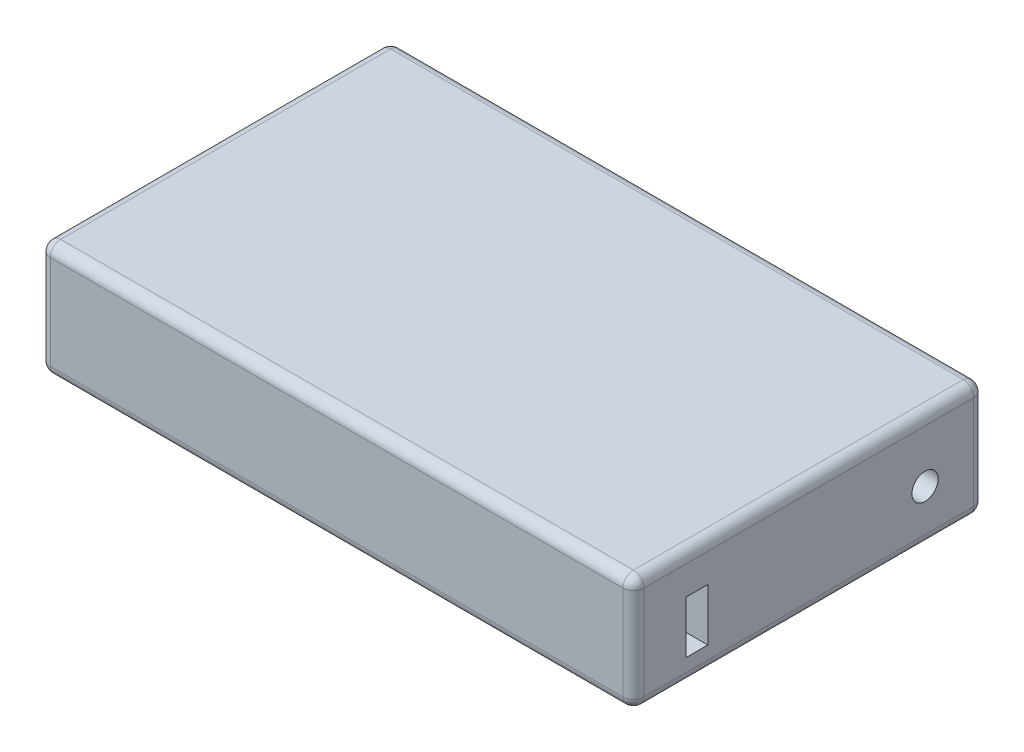
from build123d import *

# Parameters (mm, degrees)
SKETCH1_W           = 144.018
SKETCH1_H           = 85.09
BOSS_EXTRUDE1_DEPTH = 27.94
FILLET1_R           = 2.54
SKETCH3_R           = 3.175
SKETCH3_W           = 5.334
SKETCH3_H           = 12.7
CUT_EXTRUDE1_DEPTH  = 12.7


with BuildPart() as part:
    # Sketch1 → Boss-Extrude1 (new body)
    with BuildSketch(Plane(origin=(0, 0, 0), x_dir=(1, 0, 0), z_dir=(0, 1, 0))):
        Rectangle(SKETCH1_W, SKETCH1_H)
    extrude(amount=BOSS_EXTRUDE1_DEPTH)

    # Fillet1
    fillet1_edges = [part.edges().sort_by_distance(p)[0] for p in [
        (-72.009, 27.94, 0),
        (0, 27.94, 42.545),
        (72.009, 27.94, 0),
        (0, 0, 42.545),
        (-72.009, 0, 0),
        (0, 0, -42.545),
        (72.009, 0, 0),
        (72.009, 13.97, 42.545),
        (-72.009, 13.97, 42.545),
        (-72.009, 13.97, -42.545),
        (72.009, 13.97, -42.545),
        (0, 27.94, -42.545),
    ]]
    fillet(fillet1_edges, radius=FILLET1_R)

    # Sketch3 → Cut-Extrude1 (cut)
    with BuildSketch(Plane(origin=(72.009, 0, 0), x_dir=(0, 0, -1), z_dir=(1, 0, 0))):
        with Locations((28.194, 12.7)):
            Circle(SKETCH3_R)
        with Locations((-27.178, 12.065)):
            Rectangle(SKETCH3_W, SKETCH3_H)
    extrude(amount=-CUT_EXTRUDE1_DEPTH, mode=Mode.SUBTRACT)


solid = part.part
